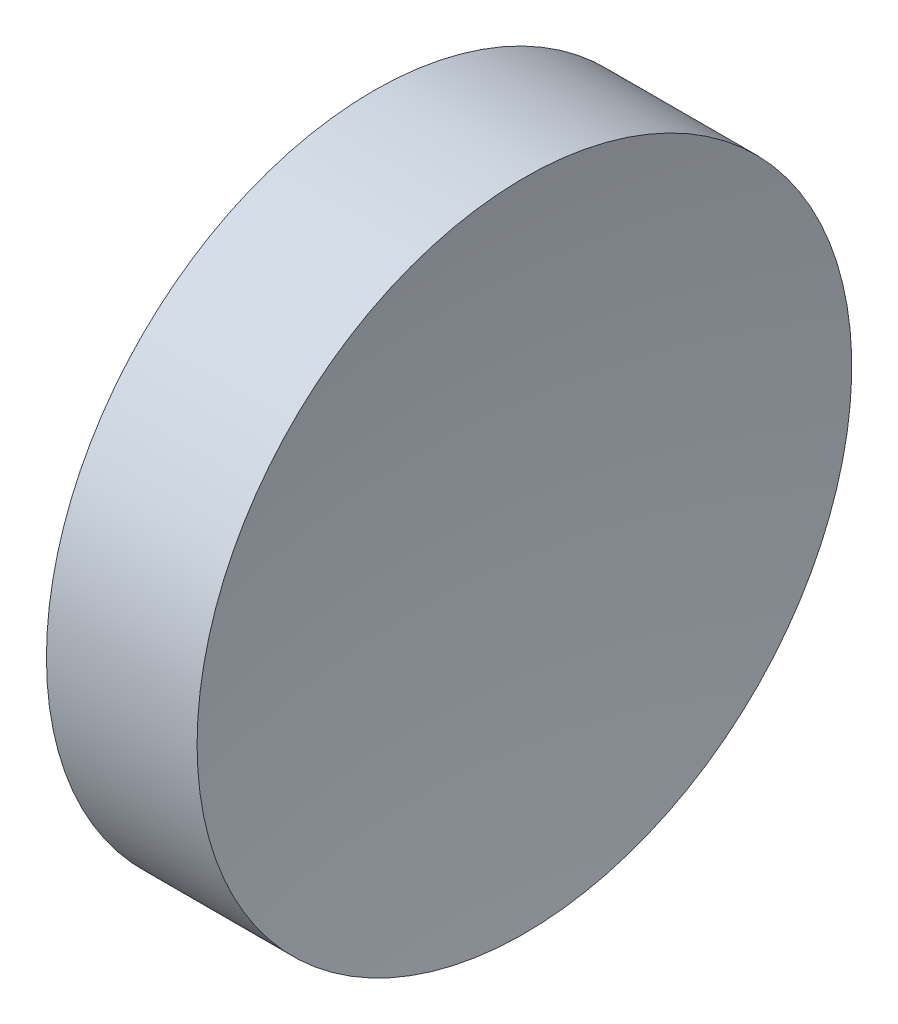
from build123d import *


with BuildPart() as part:
    # 草图1 → 旋转1 (revolve)
    with BuildSketch(Plane.XY):
        with BuildLine():
            Line((118.352703446, 65.222602873), (121.852703446, 65.222602873))
            ThreePointArc((121.852703446, 65.222602873), (122.149198109, 71.599598617), (123.028744004, 77.922602873))
            Line((123.028744004, 77.922602873), (119.97134323, 77.922602873))
            Line((119.97134323, 77.922602873), (117.184202042, 77.922602873))
            ThreePointArc((117.184202042, 77.922602873), (118.059962454, 71.599424094), (118.352703446, 65.222602873))
        make_face()
    revolve(axis=Axis((109.936935226, 65.222602873, 0), (1, 0, 0)))


solid = part.part
